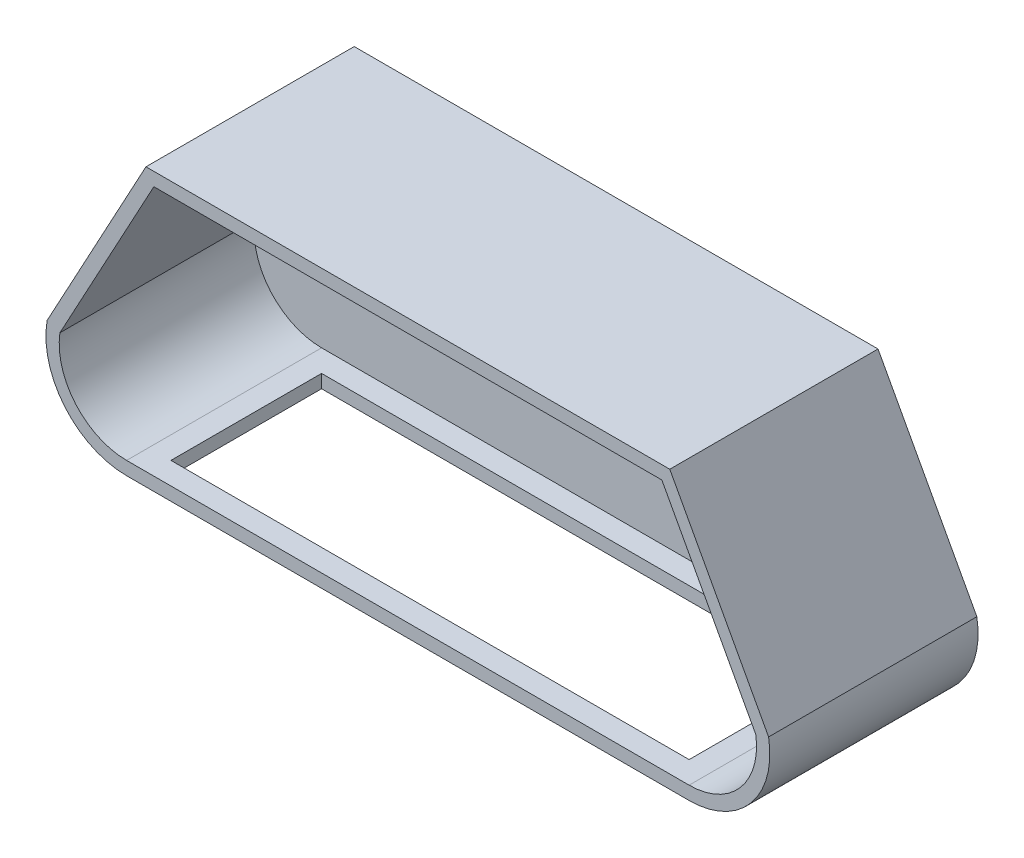
from build123d import *

# Parameters (mm, degrees)
BOSS_EXTRUDE1_DEPTH = 88
SKETCH3_W           = 233.89900304
SKETCH3_H           = 68
CUT_EXTRUDE1_DEPTH  = 15
BOSS_EXTRUDE2_DEPTH = 6


with BuildPart() as part:
    # Sketch1 → Boss-Extrude1 (new body)
    with BuildSketch(Plane.XY):
        with BuildLine():
            Line((118.214818276, 64.136748505), (-118.214818276, 64.136748505))
            Line((-118.214818276, 64.136748505), (-162.822637659, -18.216148816))
            ThreePointArc((-162.822637659, -18.216148816), (-154.866072847, -47.976045164), (-126.94950152, -61))
            Line((-126.94950152, -61), (126.94950152, -61))
            ThreePointArc((126.94950152, -61), (154.866072847, -47.976045164), (162.822637659, -18.216148816))
            Line((162.822637659, -18.216148816), (118.214818276, 64.136748505))
        make_face()
        with BuildLine():
            Line((114.641146244, 58.136748505), (-114.641146244, 58.136748505))
            Line((-114.641146244, 58.136748505), (-157.062609578, -20.179799188))
            ThreePointArc((-157.062609578, -20.179799188), (-149.967134226, -44.474777247), (-126.94950152, -55))
            Line((-126.94950152, -55), (126.94950152, -55))
            ThreePointArc((126.94950152, -55), (149.967134226, -44.474777247), (157.062609578, -20.179799188))
            Line((157.062609578, -20.179799188), (114.641146244, 58.136748505))
        make_face(mode=Mode.SUBTRACT)
    extrude(amount=BOSS_EXTRUDE1_DEPTH)

    # Sketch3 → Cut-Extrude1 (cut)
    with BuildSketch(Plane.XZ.offset(46)):
        with Locations((0, 44)):
            Rectangle(SKETCH3_W, SKETCH3_H)
    extrude(amount=CUT_EXTRUDE1_DEPTH, mode=Mode.SUBTRACT)

    # Sketch1_12 → Boss-Extrude2 (add)
    with BuildSketch(Plane.XY):
        with BuildLine():
            Line((162.822637659, -18.216148816), (118.214818276, 64.136748505))
            Line((118.214818276, 64.136748505), (-118.214818276, 64.136748505))
            Line((-118.214818276, 64.136748505), (-162.822637659, -18.216148816))
            ThreePointArc((-162.822637659, -18.216148816), (-154.866072847, -47.976045164), (-126.94950152, -61))
            Line((-126.94950152, -61), (126.94950152, -61))
            ThreePointArc((126.94950152, -61), (154.866072847, -47.976045164), (162.822637659, -18.216148816))
        make_face()
    extrude(amount=-BOSS_EXTRUDE2_DEPTH)


solid = part.part
